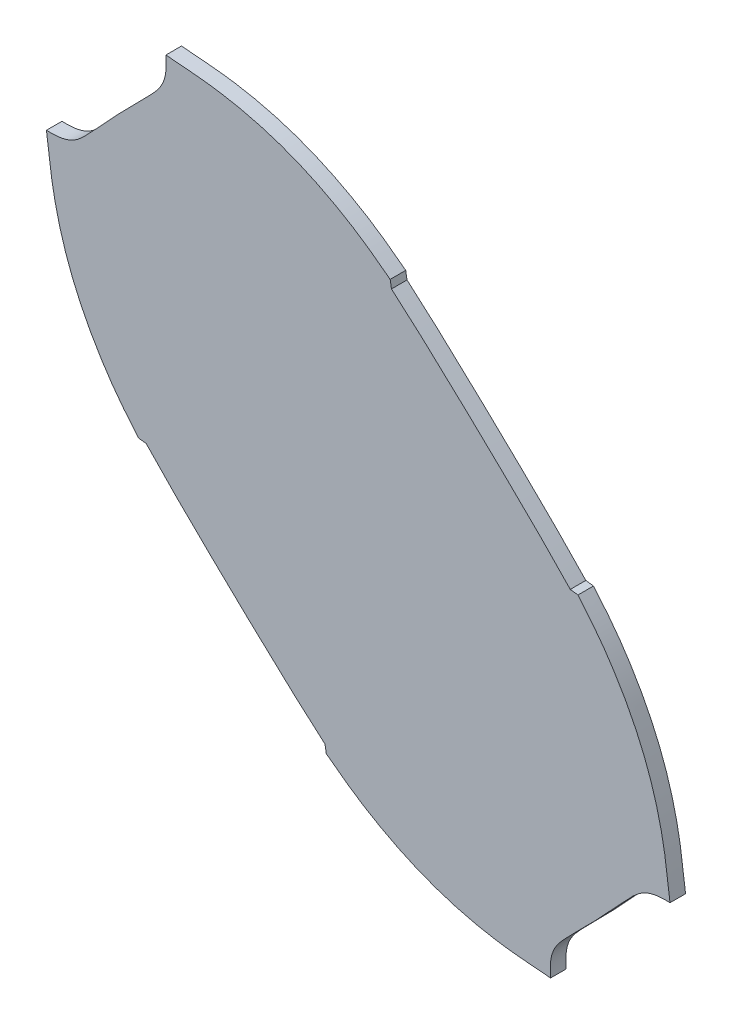
from build123d import *

# Parameters (mm, degrees)
EXTRUDE_1_DEPTH = 3


with BuildPart() as part:
    # Model → Бобышка-Вытянуть1 (new body)
    with BuildSketch(Plane.XY):
        with BuildLine():
            add(Edge.make_bspline(
                [(2.93021052, -47.035829845), (7.067392634, -50.203408799), (9.192109773, -51.661949534), (16.033912525, -55.596417645), (19.531782895, -57.247377963), (26.901706576, -59.946143344), (30.729833359, -60.954279881), (38.329709704, -62.270501958), (40.987603987, -62.444811681), (46.180399423, -62.872756714)],
                knots=[0, 0, 0, 0, 0.25, 0.25, 0.5, 0.5, 0.75, 0.75, 1, 1, 1, 1], degree=3))
            add(Edge.make_bspline(
                [(46.180399423, -62.872756714), (45.758819222, -57.695353797), (47.425592056, -56.517371281), (51.012465844, -52.822648474)],
                knots=[0, 0, 0, 0, 1, 1, 1, 1], degree=3))
            add(Edge.make_bspline(
                [(51.012465844, -52.822648474), (54.819045751, -49.003718884), (55.749845461, -48.027023084), (59.394302363, -44.053029207)],
                knots=[0, 0, 0, 0, 1, 1, 1, 1], degree=3))
            add(Edge.make_bspline(
                [(59.394302363, -44.053029207), (62.922497168, -40.306572328), (64.027232354, -38.591746706), (69.215147689, -38.786552958)],
                knots=[0, 0, 0, 0, 1, 1, 1, 1], degree=3))
            add(Edge.make_bspline(
                [(69.215147689, -38.786552958), (68.559823273, -33.614049971), (68.287529116, -31.05697886), (66.59488265, -23.333351959), (65.426938577, -19.616873752), (62.427174816, -12.420563312), (60.576503981, -8.914752048), (56.410752014, -2.359714152), (54.822950455, -0.246005976), (51.466536582, 3.743837686)],
                knots=[0, 0, 0, 0, 0.25, 0.25, 0.5, 0.5, 0.75, 0.75, 1, 1, 1, 1], degree=3))
            add(Edge.make_bspline(
                [(51.466536582, 3.743837686), (50.970330899, 3.804673675), (50.474125217, 3.865509664), (49.977918997, 3.926346223)],
                knots=[0, 0, 0, 0, 1, 1, 1, 1], degree=3))
            add(Edge.make_bspline(
                [(49.977918997, 3.926346223), (46.342202727, 7.78345872), (44.298418779, 9.797169906), (38.948827381, 15.075374053), (35.988080117, 17.943328603), (30.136171062, 23.533872679), (27.409247326, 26.107876823), (21.345767872, 31.71622684), (19.515288118, 33.414658565), (15.493611073, 36.867480358)],
                knots=[0, 0, 0, 0, 0.25, 0.25, 0.5, 0.5, 0.75, 0.75, 1, 1, 1, 1], degree=3))
            add(Edge.make_bspline(
                [(15.493611073, 36.867480358), (15.410547933, 37.360005635), (15.327484793, 37.852530912), (15.244421071, 38.345056635)],
                knots=[0, 0, 0, 0, 1, 1, 1, 1], degree=3))
            add(Edge.make_bspline(
                [(15.244421071, 38.345056635), (11.108187375, 41.514140361), (8.984789105, 42.976044064), (2.145370456, 46.912195843), (-1.353124309, 48.564383816), (-8.722349322, 51.264624949), (-12.550903021, 52.273639492), (-20.150103838, 53.591559824), (-22.808358534, 53.766364957), (-28.001098537, 54.197041453)],
                knots=[0, 0, 0, 0, 0.25, 0.25, 0.5, 0.5, 0.75, 0.75, 1, 1, 1, 1], degree=3))
            add(Edge.make_bspline(
                [(-28.001098537, 54.197041453), (-27.582231733, 49.017972156), (-29.250606315, 47.841029904), (-32.8393479, 44.146128414)],
                knots=[0, 0, 0, 0, 1, 1, 1, 1], degree=3))
            add(Edge.make_bspline(
                [(-32.8393479, 44.146128414), (-36.647524986, 40.326630555), (-37.578469348, 39.349528956), (-41.224035005, 35.374474336)],
                knots=[0, 0, 0, 0, 1, 1, 1, 1], degree=3))
            add(Edge.make_bspline(
                [(-41.224035005, 35.374474336), (-44.752541009, 31.62695264), (-45.856901974, 29.91117122), (-51.045858414, 30.105043834)],
                knots=[0, 0, 0, 0, 1, 1, 1, 1], degree=3))
            add(Edge.make_bspline(
                [(-51.045858414, 30.105043834), (-50.389579788, 24.932244901), (-50.117422171, 22.37506422), (-48.424572599, 14.650618487), (-47.256661176, 10.934049352), (-44.25648622, 3.736968832), (-42.406315611, 0.232073048), (-38.237929287, -6.32500722), (-36.648825155, -8.436432959), (-33.291264991, -12.425853712)],
                knots=[0, 0, 0, 0, 0.25, 0.25, 0.5, 0.5, 0.75, 0.75, 1, 1, 1, 1], degree=3))
            add(Edge.make_bspline(
                [(-33.291264991, -12.425853712), (-32.795507537, -12.485938527), (-32.299750083, -12.546023343), (-31.803992094, -12.606108726)],
                knots=[0, 0, 0, 0, 1, 1, 1, 1], degree=3))
            add(Edge.make_bspline(
                [(-31.803992094, -12.606108726), (-28.170279016, -16.466143921), (-26.126623202, -18.477365459), (-20.773889604, -23.760459388), (-17.816009711, -26.626804665), (-11.962306891, -32.22132381), (-9.236316952, -34.795481786), (-3.173396654, -40.405117229), (-1.343127714, -42.10485992), (2.679867651, -45.557297003)],
                knots=[0, 0, 0, 0, 0.25, 0.25, 0.5, 0.5, 0.75, 0.75, 1, 1, 1, 1], degree=3))
            add(Edge.make_bspline(
                [(2.679867651, -45.557297003), (2.763315274, -46.050141284), (2.846762897, -46.542985564), (2.93021052, -47.035829845)],
                knots=[0, 0, 0, 0, 1, 1, 1, 1], degree=3))
        make_face()
    extrude(amount=EXTRUDE_1_DEPTH)


solid = part.part
